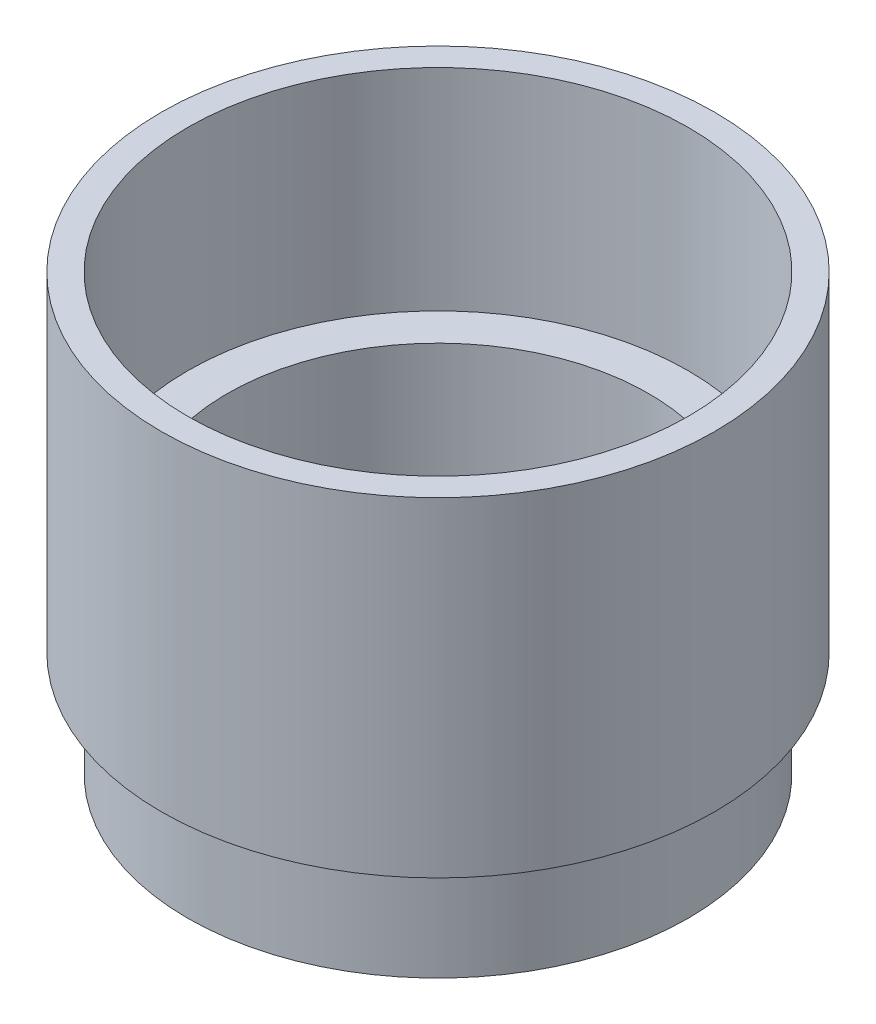
from build123d import *

# Parameters (mm, degrees)
SKETCH2_W          = 38.1
SKETCH2_H          = 19.05
CUT_EXTRUDE1_DEPTH = 5.08
FILLET1_R          = 4.7625


with BuildPart() as part:
    # Sketch1 → Revolve1 (revolve)
    with BuildSketch(Plane.XY):
        Polygon((0, 0), (25.4, 0), (25.4, 19.05), (30.1625, 19.05), (30.1625, 44.45), (33.3375, 44.45), (33.3375, 4.7625), (30.1625, 4.7625), (30.1625, -7.9375), (0, -7.9375), align=None)
    revolve(axis=Axis((0, 0, 0), (0, -1, 0)))

    # Sketch2 → Cut-Extrude1 (cut)
    with BuildSketch(Plane(origin=(0, 0, 0), x_dir=(1, 0, 0), z_dir=(0, 1, 0))):
        Rectangle(SKETCH2_W, SKETCH2_H)
    extrude(amount=-CUT_EXTRUDE1_DEPTH, mode=Mode.SUBTRACT)

    # Fillet1
    fillet1_edges = [part.edges().sort_by_distance(p)[0] for p in [
        (19.05, -2.54, -9.525),
        (19.05, -2.54, 9.525),
        (-19.05, -2.54, 9.525),
        (-19.05, -2.54, -9.525),
    ]]
    fillet(fillet1_edges, radius=FILLET1_R)


solid = part.part
